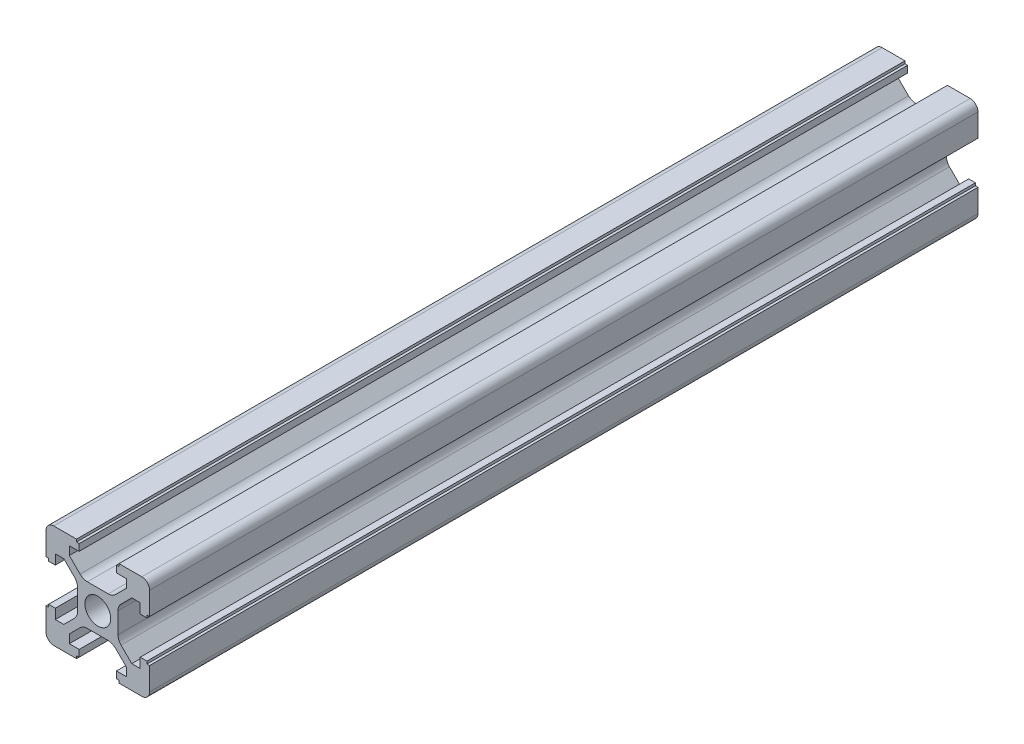
from build123d import *

# Parameters (mm, degrees)
SKETCH1_R           = 2.5
BOSS_EXTRUDE2_DEPTH = 160


with BuildPart() as part:
    # Sketch1 → Boss-Extrude2 (new body)
    with BuildSketch(Plane.XY):
        with BuildLine():
            Line((10, -4.1), (10, -8.5))
            ThreePointArc((10, -8.5), (9.560660172, -9.560660172), (8.5, -10))
            Line((8.5, -10), (4.1, -10))
            Line((4.1, -10), (4.1, -9.5))
            Line((4.1, -9.5), (3.6, -9.5))
            Line((3.6, -9.5), (3.6, -8.2))
            Line((3.6, -8.2), (5.5, -8.2))
            Line((5.5, -8.2), (5.5, -6.560660172))
            Line((5.5, -6.560660172), (3.425126266, -4.485786438))
            ThreePointArc((3.425126266, -4.485786438), (2.776279568, -4.052240935), (2.010912703, -3.9))
            Line((2.010912703, -3.9), (-2.010912703, -3.9))
            ThreePointArc((-2.010912703, -3.9), (-2.776279568, -4.052240935), (-3.425126266, -4.485786438))
            Line((-3.425126266, -4.485786438), (-5.5, -6.560660172))
            Line((-5.5, -6.560660172), (-5.5, -8.2))
            Line((-5.5, -8.2), (-3.6, -8.2))
            Line((-3.6, -8.2), (-3.6, -9.5))
            Line((-3.6, -9.5), (-4.1, -9.5))
            Line((-4.1, -9.5), (-4.1, -10))
            Line((-4.1, -10), (-8.5, -10))
            ThreePointArc((-8.5, -10), (-9.560660172, -9.560660172), (-10, -8.5))
            Line((-10, -8.5), (-10, -4.1))
            Line((-10, -4.1), (-9.5, -4.1))
            Line((-9.5, -4.1), (-9.5, -3.6))
            Line((-9.5, -3.6), (-8.2, -3.6))
            Line((-8.2, -3.6), (-8.2, -5.5))
            Line((-8.2, -5.5), (-6.560660172, -5.5))
            Line((-6.560660172, -5.5), (-4.485786438, -3.425126266))
            ThreePointArc((-4.485786438, -3.425126266), (-4.052240935, -2.776279568), (-3.9, -2.010912703))
            Line((-3.9, -2.010912703), (-3.9, 2.010912703))
            ThreePointArc((-3.9, 2.010912703), (-4.052240935, 2.776279568), (-4.485786438, 3.425126266))
            Line((-4.485786438, 3.425126266), (-6.560660172, 5.5))
            Line((-6.560660172, 5.5), (-8.2, 5.5))
            Line((-8.2, 5.5), (-8.2, 3.6))
            Line((-8.2, 3.6), (-9.5, 3.6))
            Line((-9.5, 3.6), (-9.5, 4.1))
            Line((-9.5, 4.1), (-10, 4.1))
            Line((-10, 4.1), (-10, 8.5))
            ThreePointArc((-10, 8.5), (-9.560660172, 9.560660172), (-8.5, 10))
            Line((-8.5, 10), (-4.1, 10))
            Line((-4.1, 10), (-4.1, 9.5))
            Line((-4.1, 9.5), (-3.6, 9.5))
            Line((-3.6, 9.5), (-3.6, 8.2))
            Line((-3.6, 8.2), (-5.5, 8.2))
            Line((-5.5, 8.2), (-5.5, 6.560660172))
            Line((-5.5, 6.560660172), (-3.425126266, 4.485786438))
            ThreePointArc((-3.425126266, 4.485786438), (-2.776279568, 4.052240935), (-2.010912703, 3.9))
            Line((-2.010912703, 3.9), (2.010912703, 3.9))
            ThreePointArc((2.010912703, 3.9), (2.776279568, 4.052240935), (3.425126266, 4.485786438))
            Line((3.425126266, 4.485786438), (5.5, 6.560660172))
            Line((5.5, 6.560660172), (5.5, 8.2))
            Line((5.5, 8.2), (3.6, 8.2))
            Line((3.6, 8.2), (3.6, 9.5))
            Line((3.6, 9.5), (4.1, 9.5))
            Line((4.1, 9.5), (4.1, 10))
            Line((4.1, 10), (8.5, 10))
            ThreePointArc((8.5, 10), (9.560660172, 9.560660172), (10, 8.5))
            Line((10, 8.5), (10, 4.1))
            Line((10, 4.1), (9.5, 4.1))
            Line((9.5, 4.1), (9.5, 3.6))
            Line((9.5, 3.6), (8.2, 3.6))
            Line((8.2, 3.6), (8.2, 5.5))
            Line((8.2, 5.5), (6.560660172, 5.5))
            Line((6.560660172, 5.5), (4.485786438, 3.425126266))
            ThreePointArc((4.485786438, 3.425126266), (4.052240935, 2.776279568), (3.9, 2.010912703))
            Line((3.9, 2.010912703), (3.9, -2.010912703))
            ThreePointArc((3.9, -2.010912703), (4.052240935, -2.776279568), (4.485786438, -3.425126266))
            Line((4.485786438, -3.425126266), (6.560660172, -5.5))
            Line((6.560660172, -5.5), (8.2, -5.5))
            Line((8.2, -5.5), (8.2, -3.6))
            Line((8.2, -3.6), (9.5, -3.6))
            Line((9.5, -3.6), (9.5, -4.1))
            Line((9.5, -4.1), (10, -4.1))
        make_face()
        Circle(SKETCH1_R, mode=Mode.SUBTRACT)
    extrude(amount=BOSS_EXTRUDE2_DEPTH)


solid = part.part
